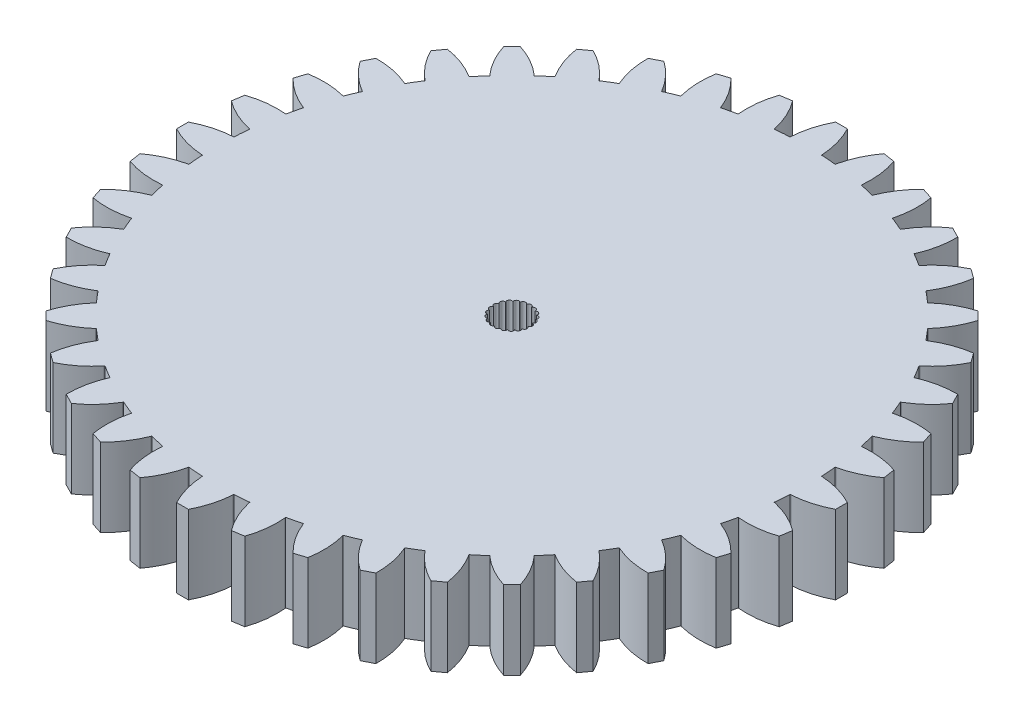
from build123d import *

# Parameters (mm, degrees)
BOSS_EXTRUDE1_DEPTH = 10
BOSS_EXTRUDE2_DEPTH = 10
CIRPATTERN1_COUNT   = 40


with BuildPart() as part:
    # Sketch2 → Boss-Extrude1 (new body)
    with BuildSketch(Plane(origin=(0, 0, 0), x_dir=(1, 0, 0), z_dir=(0, 1, 0))):
        with BuildLine():
            ThreePointArc((3.887214812, 37.297983337), (2.94221609, 37.384400015), (1.995333323, 37.446877639))
            ThreePointArc((1.995333323, 37.446877639), (0, 37.5), (-1.995333323, 37.446877639))
            ThreePointArc((-1.995333323, 37.446877639), (-2.94221609, 37.384400015), (-3.887214812, 37.297983337))
            ThreePointArc((-3.887214812, 37.297983337), (-5.866292439, 37.038312772), (-7.82874973, 36.673705535))
            ThreePointArc((-7.82874973, 36.673705535), (-8.754201145, 36.463872015), (-9.674046817, 36.2306889))
            ThreePointArc((-9.674046817, 36.2306889), (-11.588137289, 35.664619361), (-13.469396336, 34.997505087))
            ThreePointArc((-13.469396336, 34.997505087), (-14.350628714, 34.645482469), (-15.222671684, 34.27127466))
            ThreePointArc((-15.222671684, 34.27127466), (-17.02464374, 33.412744657), (-18.778381702, 32.459549914))
            ThreePointArc((-18.778381702, 32.459549914), (-19.593696177, 31.974006163), (-20.396463853, 31.467987897))
            ThreePointArc((-20.396463853, 31.467987897), (-22.041946961, 30.338137289), (-23.624980989, 29.122332896))
            ThreePointArc((-23.624980989, 29.122332896), (-24.354301812, 28.51522371), (-25.068027389, 27.889854837))
            ThreePointArc((-25.068027389, 27.889854837), (-26.516504294, 26.516504294), (-27.889854837, 25.068027389))
            ThreePointArc((-27.889854837, 25.068027389), (-28.51522371, 24.354301812), (-29.122332896, 23.624980989))
            ThreePointArc((-29.122332896, 23.624980989), (-30.338137289, 22.041946961), (-31.467987897, 20.396463853))
            ThreePointArc((-31.467987897, 20.396463853), (-31.974006163, 19.593696177), (-32.459549914, 18.778381702))
            ThreePointArc((-32.459549914, 18.778381702), (-33.412744657, 17.02464374), (-34.27127466, 15.222671684))
            ThreePointArc((-34.27127466, 15.222671684), (-34.645482469, 14.350628714), (-34.997505087, 13.469396336))
            ThreePointArc((-34.997505087, 13.469396336), (-35.664619361, 11.588137289), (-36.2306889, 9.674046817))
            ThreePointArc((-36.2306889, 9.674046817), (-36.463872015, 8.754201145), (-36.673705535, 7.82874973))
            ThreePointArc((-36.673705535, 7.82874973), (-37.038312772, 5.866292439), (-37.297983337, 3.887214812))
            ThreePointArc((-37.297983337, 3.887214812), (-37.384400015, 2.94221609), (-37.446877639, 1.995333323))
            ThreePointArc((-37.446877639, 1.995333323), (-37.5, 0), (-37.446877639, -1.995333323))
            ThreePointArc((-37.446877639, -1.995333323), (-37.384400015, -2.94221609), (-37.297983337, -3.887214812))
            ThreePointArc((-37.297983337, -3.887214812), (-37.038312772, -5.866292439), (-36.673705535, -7.82874973))
            ThreePointArc((-36.673705535, -7.82874973), (-36.463872015, -8.754201145), (-36.2306889, -9.674046817))
            ThreePointArc((-36.2306889, -9.674046817), (-35.664619361, -11.588137289), (-34.997505087, -13.469396336))
            ThreePointArc((-34.997505087, -13.469396336), (-34.645482469, -14.350628714), (-34.27127466, -15.222671684))
            ThreePointArc((-34.27127466, -15.222671684), (-33.412744657, -17.02464374), (-32.459549914, -18.778381702))
            ThreePointArc((-32.459549914, -18.778381702), (-31.974006163, -19.593696177), (-31.467987897, -20.396463853))
            ThreePointArc((-31.467987897, -20.396463853), (-30.338137289, -22.041946961), (-29.122332896, -23.624980989))
            ThreePointArc((-29.122332896, -23.624980989), (-28.51522371, -24.354301812), (-27.889854837, -25.068027389))
            ThreePointArc((-27.889854837, -25.068027389), (-26.516504294, -26.516504295), (-25.068027389, -27.889854837))
            ThreePointArc((-25.068027389, -27.889854837), (-24.354301812, -28.51522371), (-23.624980989, -29.122332896))
            ThreePointArc((-23.624980989, -29.122332896), (-22.041946961, -30.338137289), (-20.396463853, -31.467987897))
            ThreePointArc((-20.396463853, -31.467987897), (-19.593696177, -31.974006163), (-18.778381702, -32.459549914))
            ThreePointArc((-18.778381702, -32.459549914), (-17.02464374, -33.412744657), (-15.222671684, -34.27127466))
            ThreePointArc((-15.222671684, -34.27127466), (-14.350628714, -34.645482469), (-13.469396336, -34.997505087))
            ThreePointArc((-13.469396336, -34.997505087), (-11.588137289, -35.664619361), (-9.674046817, -36.2306889))
            ThreePointArc((-9.674046817, -36.2306889), (-8.754201145, -36.463872015), (-7.82874973, -36.673705535))
            ThreePointArc((-7.82874973, -36.673705535), (-5.866292439, -37.038312772), (-3.887214812, -37.297983337))
            ThreePointArc((-3.887214812, -37.297983337), (-2.94221609, -37.384400015), (-1.995333323, -37.446877639))
            ThreePointArc((-1.995333323, -37.446877639), (0, -37.5), (1.995333323, -37.446877639))
            ThreePointArc((1.995333323, -37.446877639), (2.94221609, -37.384400015), (3.887214812, -37.297983337))
            ThreePointArc((3.887214812, -37.297983337), (5.866292439, -37.038312772), (7.82874973, -36.673705535))
            ThreePointArc((7.82874973, -36.673705535), (8.754201145, -36.463872015), (9.674046817, -36.2306889))
            ThreePointArc((9.674046817, -36.2306889), (11.588137289, -35.664619361), (13.469396336, -34.997505087))
            ThreePointArc((13.469396336, -34.997505087), (14.350628714, -34.645482469), (15.222671684, -34.27127466))
            ThreePointArc((15.222671684, -34.27127466), (17.02464374, -33.412744657), (18.778381702, -32.459549914))
            ThreePointArc((18.778381702, -32.459549914), (19.593696177, -31.974006163), (20.396463853, -31.467987897))
            ThreePointArc((20.396463853, -31.467987897), (22.041946961, -30.338137289), (23.624980989, -29.122332896))
            ThreePointArc((23.624980989, -29.122332896), (24.354301812, -28.51522371), (25.068027389, -27.889854837))
            ThreePointArc((25.068027389, -27.889854837), (26.516504295, -26.516504294), (27.889854837, -25.068027389))
            ThreePointArc((27.889854837, -25.068027389), (28.51522371, -24.354301812), (29.122332896, -23.624980989))
            ThreePointArc((29.122332896, -23.624980989), (30.338137289, -22.041946961), (31.467987897, -20.396463853))
            ThreePointArc((31.467987897, -20.396463853), (31.974006163, -19.593696177), (32.459549914, -18.778381702))
            ThreePointArc((32.459549914, -18.778381702), (33.412744657, -17.02464374), (34.27127466, -15.222671684))
            ThreePointArc((34.27127466, -15.222671684), (34.645482469, -14.350628714), (34.997505087, -13.469396336))
            ThreePointArc((34.997505087, -13.469396336), (35.664619361, -11.588137289), (36.2306889, -9.674046817))
            ThreePointArc((36.2306889, -9.674046817), (36.463872015, -8.754201145), (36.673705535, -7.82874973))
            ThreePointArc((36.673705535, -7.82874973), (37.038312772, -5.866292439), (37.297983337, -3.887214812))
            ThreePointArc((37.297983337, -3.887214812), (37.384400015, -2.94221609), (37.446877639, -1.995333323))
            ThreePointArc((37.446877639, -1.995333323), (37.486717057, -0.998020172), (37.5, 0))
            ThreePointArc((37.5, 0), (37.486717057, 0.998020172), (37.446877639, 1.995333323))
            ThreePointArc((37.446877639, 1.995333323), (37.384400015, 2.94221609), (37.297983337, 3.887214812))
            ThreePointArc((37.297983337, 3.887214812), (37.038312772, 5.866292439), (36.673705535, 7.82874973))
            ThreePointArc((36.673705535, 7.82874973), (36.463872015, 8.754201145), (36.2306889, 9.674046817))
            ThreePointArc((36.2306889, 9.674046817), (35.664619361, 11.588137289), (34.997505087, 13.469396336))
            ThreePointArc((34.997505087, 13.469396336), (34.645482469, 14.350628714), (34.27127466, 15.222671684))
            ThreePointArc((34.27127466, 15.222671684), (33.412744657, 17.02464374), (32.459549914, 18.778381702))
            ThreePointArc((32.459549914, 18.778381702), (31.974006163, 19.593696177), (31.467987897, 20.396463853))
            ThreePointArc((31.467987897, 20.396463853), (30.338137289, 22.041946961), (29.122332896, 23.624980989))
            ThreePointArc((29.122332896, 23.624980989), (28.51522371, 24.354301812), (27.889854837, 25.068027389))
            ThreePointArc((27.889854837, 25.068027389), (26.516504294, 26.516504294), (25.068027389, 27.889854837))
            ThreePointArc((25.068027389, 27.889854837), (24.354301812, 28.51522371), (23.624980989, 29.122332896))
            ThreePointArc((23.624980989, 29.122332896), (22.041946961, 30.338137289), (20.396463853, 31.467987897))
            ThreePointArc((20.396463853, 31.467987897), (19.593696177, 31.974006163), (18.778381702, 32.459549914))
            ThreePointArc((18.778381702, 32.459549914), (17.02464374, 33.412744657), (15.222671684, 34.27127466))
            ThreePointArc((15.222671684, 34.27127466), (14.350628714, 34.645482469), (13.469396336, 34.997505087))
            ThreePointArc((13.469396336, 34.997505087), (11.588137289, 35.664619361), (9.674046817, 36.2306889))
            ThreePointArc((9.674046817, 36.2306889), (8.754201145, 36.463872015), (7.82874973, 36.673705535))
            ThreePointArc((7.82874973, 36.673705535), (5.866292439, 37.038312772), (3.887214812, 37.297983337))
        make_face()
        with BuildLine():
            ThreePointArc((1.905255888, 1.1), (2.280640684, 0.89508551), (2.144841407, 0.489546055))
            ThreePointArc((2.144841407, 0.489546055), (2.443149303, 0.183088729), (2.193848354, -0.164406206))
            ThreePointArc((2.193848354, -0.164406206), (2.388573385, -0.545176288), (2.047922247, -0.803750254))
            ThreePointArc((2.047922247, -0.803750254), (2.121762239, -1.225), (1.720029261, -1.371677564))
            ThreePointArc((1.720029261, -1.371677564), (1.666423208, -1.795977086), (1.239304128, -1.817725303))
            ThreePointArc((1.239304128, -1.817725303), (1.063015161, -2.207373726), (0.648461384, -2.102260173))
            ThreePointArc((0.648461384, -2.102260173), (0.365153552, -2.422635524), (0, -2.2))
            ThreePointArc((0, -2.2), (-0.365153552, -2.422635524), (-0.648461384, -2.102260173))
            ThreePointArc((-0.648461384, -2.102260173), (-1.063015161, -2.207373726), (-1.239304128, -1.817725303))
            ThreePointArc((-1.239304128, -1.817725303), (-1.666423208, -1.795977086), (-1.720029261, -1.371677564))
            ThreePointArc((-1.720029261, -1.371677564), (-2.121762239, -1.225), (-2.047922247, -0.803750254))
            ThreePointArc((-2.047922247, -0.803750254), (-2.388573385, -0.545176288), (-2.193848354, -0.164406206))
            ThreePointArc((-2.193848354, -0.164406206), (-2.443149303, 0.183088729), (-2.144841407, 0.489546055))
            ThreePointArc((-2.144841407, 0.489546055), (-2.280640684, 0.89508551), (-1.905255888, 1.1))
            ThreePointArc((-1.905255888, 1.1), (-1.915487132, 1.527550015), (-1.496380023, 1.612714118))
            ThreePointArc((-1.496380023, 1.612714118), (-1.380134142, 2.024284997), (-0.954544226, 1.982131509))
            ThreePointArc((-0.954544226, 1.982131509), (-0.722150177, 2.341153374), (-0.327892986, 2.175427818))
            ThreePointArc((-0.327892986, 2.175427818), (0, 2.45), (0.327892986, 2.175427818))
            ThreePointArc((0.327892986, 2.175427818), (0.722150177, 2.341153374), (0.954544226, 1.982131509))
            ThreePointArc((0.954544226, 1.982131509), (1.380134142, 2.024284997), (1.496380023, 1.612714118))
            ThreePointArc((1.496380023, 1.612714118), (1.915487132, 1.527550015), (1.905255888, 1.1))
        make_face(mode=Mode.SUBTRACT)
    extrude(amount=BOSS_EXTRUDE1_DEPTH)

    # Sketch2_4 → Boss-Extrude2 (add)
    with BuildSketch(Plane(origin=(0, 0, 0), x_dir=(1, 0, 0), z_dir=(0, 1, 0))):
        with BuildLine():
            Line((1.995333323, 37.446877639), (2, 37.534458228))
            ThreePointArc((2, 37.534458228), (1.610422964, 39.8298795), (0.75, 41.993303038))
            Line((0.75, 41.993303038), (-0.75, 41.993303038))
            ThreePointArc((-0.75, 41.993303038), (-1.610422964, 39.8298795), (-2, 37.534458228))
            Line((-2, 37.534458228), (-1.995333323, 37.446877639))
            ThreePointArc((-1.995333323, 37.446877639), (0, 37.5), (1.995333323, 37.446877639))
        make_face()
    boss_extrude2 = extrude(amount=BOSS_EXTRUDE2_DEPTH)

    # CirPattern1: Boss-Extrude2 ×40 about axis
    cirpattern1_axis = Axis((0, 10, 0), (0, 1, 0))
    for i in range(1, CIRPATTERN1_COUNT):
        add(boss_extrude2.rotate(cirpattern1_axis, i * 360 / CIRPATTERN1_COUNT))


solid = part.part
